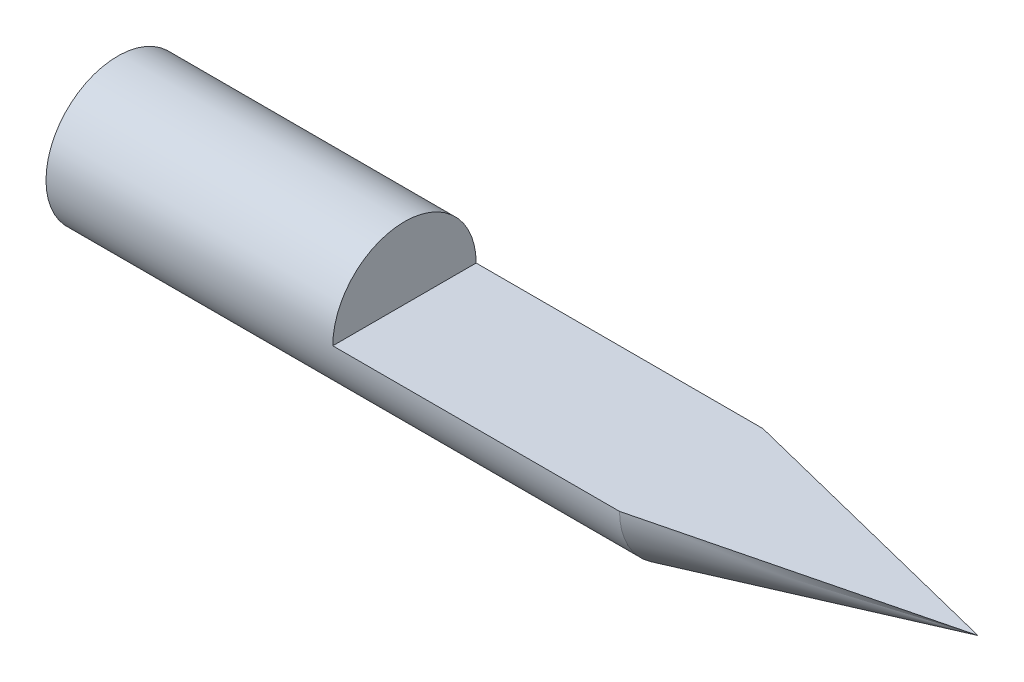
from build123d import *

# Parameters (mm, degrees)
CUT_EXTRUDE1_DEPTH = 10


with BuildPart() as part:
    # Sketch1 → Revolve2 (revolve)
    with BuildSketch(Plane.XY):
        Polygon((15, -1.25), (5, 1.25), (-15, 1.25), (-15, -1.25), align=None)
    revolve(axis=Axis((-15, -1.25, 0), (1, 0, 0)))

    # Sketch2 → Cut-Extrude1 (cut, symmetric)
    with BuildSketch(Plane(origin=(5, 0, 0), x_dir=(0, 0, -1), z_dir=(1, 0, 0))):
        with BuildLine():
            Line((-2.5, -1.25), (2.5, -1.25))
            ThreePointArc((2.5, -1.25), (0, 1.25), (-2.5, -1.25))
        make_face()
    extrude(amount=CUT_EXTRUDE1_DEPTH, both=True, mode=Mode.SUBTRACT)


solid = part.part
